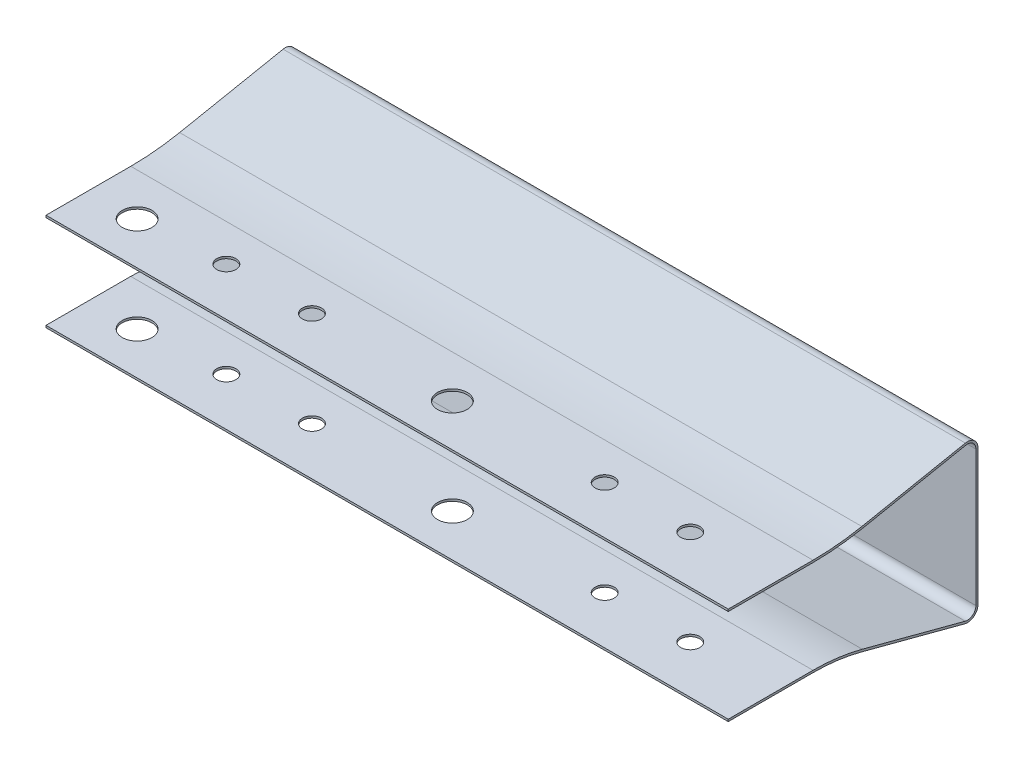
from build123d import *

# Parameters (mm, degrees)
EXTRUDE1_DEPTH          = 40.25
SKETCH2_R               = 1.75
SKETCH2_R_2             = 1.125
CUT_EXTRUDE1_DEPTH      = 10.25
CUT_EXTRUDE1_DEPTH_BACK = 10.25


with BuildPart() as part:
    # Sketch1 → Extrude1 (new body, symmetric)
    with BuildSketch(Plane(origin=(0, 0, 0), x_dir=(0, 0, -1), z_dir=(1, 0, 0))):
        with BuildLine():
            Line((-24.22, 8), (-24.22, -8))
            ThreePointArc((-24.22, -8), (-23.830111825, -8.792315317), (-22.964472878, -8.966801888))
            Line((-22.964472878, -8.966801888), (-10.813561051, -5.755298505))
            ThreePointArc((-10.813561051, -5.755298505), (-7.931209986, -5.189614776), (-5, -5))
            Line((-5, -5), (5, -5))
            Line((5, -5), (5, -5.25))
            Line((5, -5.25), (-5, -5.25))
            ThreePointArc((-5, -5.25), (-7.899000655, -5.437531211), (-10.749679271, -5.996998977))
            Line((-10.749679271, -5.996998977), (-22.900591097, -9.208502359))
            ThreePointArc((-22.900591097, -9.208502359), (-23.982639781, -8.990394146), (-24.47, -8))
            Line((-24.47, -8), (-24.47, 8))
            ThreePointArc((-24.47, 8), (-24.013634161, 8.965735377), (-22.97776829, 9.226304937))
            Line((-22.97776829, 9.226304937), (-10.765114709, 6.8139425))
            ThreePointArc((-10.765114709, 6.8139425), (-7.896315709, 6.391321284), (-5, 6.25))
            Line((-5, 6.25), (5, 6.25))
            Line((5, 6.25), (5, 6))
            Line((5, 6), (-5, 6))
            ThreePointArc((-5, 6), (-7.920654497, 6.142508858), (-10.813561051, 6.568681513))
            Line((-10.813561051, 6.568681513), (-23.026214632, 8.98104395))
            ThreePointArc((-23.026214632, 8.98104395), (-23.854907329, 8.772588302), (-24.22, 8))
        make_face()
    extrude(amount=EXTRUDE1_DEPTH, both=True)

    # Sketch2 → Cut-Extrude1 (cut, two sides)
    with BuildSketch(Plane(origin=(0, 0, 0), x_dir=(1, 0, 0), z_dir=(0, 1, 0))) as cut_extrude1_sk:
        with Locations(Location((-34.5, 0, 0), (0, 0, 270))):  # turned: the seam where the file's is
            Circle(SKETCH2_R)
        with Locations(Location((-24.62, -0.65, 0), (0, 0, 270))):  # turned: the seam where the file's is
            Circle(SKETCH2_R_2)
        with Locations(Location((-14.52, -0.65, 0), (0, 0, 270))):  # turned: the seam where the file's is
            Circle(SKETCH2_R_2)
        with Locations(Location((2.7, 0, 0), (0, 0, 270))):  # turned: the seam where the file's is
            Circle(SKETCH2_R)
        with Locations(Location((20.02, -0.65, 0), (0, 0, 270))):  # turned: the seam where the file's is
            Circle(SKETCH2_R_2)
        with Locations(Location((30.12, -0.65, 0), (0, 0, 270))):  # turned: the seam where the file's is
            Circle(SKETCH2_R_2)
    extrude(amount=CUT_EXTRUDE1_DEPTH, mode=Mode.SUBTRACT)
    extrude(cut_extrude1_sk.sketch, amount=-CUT_EXTRUDE1_DEPTH_BACK, mode=Mode.SUBTRACT)


with BuildPart() as body_2:
    # Mirror4: mirrored copy
    add(part.part.mirror(Plane.XY))


solid = body_2.part
